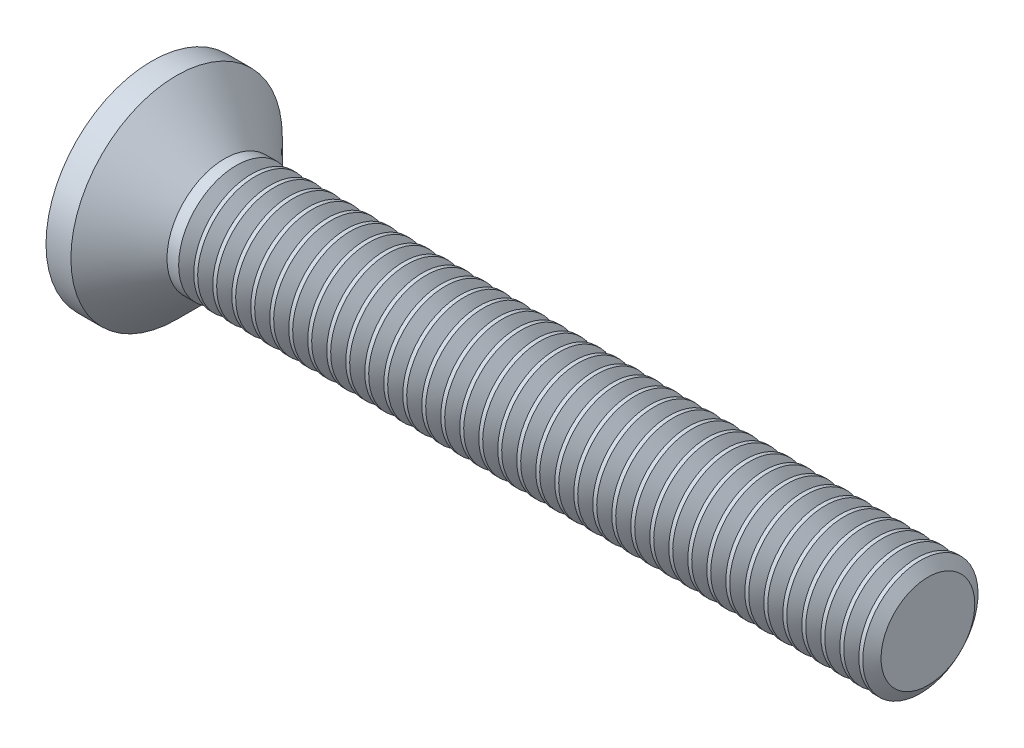
from build123d import *

# Parameters (mm, degrees)
SKETCH3_W         = 0.83
SKETCH3_H         = 3.44
SKETCH4_W         = 0.415
SKETCH4_H         = 0.415
CIRPATTERN1_COUNT = 2
CIRPATTERN1_ANGLE = 90
THDSCHPAT_COUNT   = 37
THDSCHPAT_PITCH   = 0.494444444


with BuildPart() as part:
    # BodySke → Base-Revolve (revolve)
    with BuildSketch(Plane.XY):
        with BuildLine():
            Line((0, 0), (20.727669073, 0))
            Line((20.727669073, 0), (20.727669073, 1.5))
            Line((20.727669073, 1.5), (2.427669073, 1.5))
            Line((2.427669073, 1.5), (1.177669073, 2.75))
            Line((1.177669073, 2.75), (0.529956332, 2.75))
            ThreePointArc((0.529956332, 2.75), (0.133696843, 1.400299407), (0, 0))
        make_face()
    revolve(axis=Axis((-15.875, 0, 0), (1, 0, 0)))

    # Sketch3 → Cross section 0
    with BuildSketch(Plane(origin=(0, 0, 0), x_dir=(0, 0, -1), z_dir=(1, 0, 0))):
        Rectangle(SKETCH3_W, SKETCH3_H)
    # Sketch4 → Cross section 1
    with BuildSketch(Plane(origin=(2.33, 0, 0), x_dir=(0, 0, -1), z_dir=(1, 0, 0))):
        Rectangle(SKETCH4_W, SKETCH4_H)
    cross = loft(mode=Mode.SUBTRACT)

    # CirPattern1: Cross ×2 about axis
    cirpattern1_axis = Axis((0, 0, 0), (1, 0, 0))
    for i in range(1, CIRPATTERN1_COUNT):
        add(cross.rotate(cirpattern1_axis, i * CIRPATTERN1_ANGLE / (CIRPATTERN1_COUNT - 1)), mode=Mode.SUBTRACT)

    # ThdSchSke → ThreadSchematic (revolve, cut)
    with BuildSketch(Plane.XY):
        Polygon((2.927669073, -1.2195), (2.731260858, -1.5), (2.731260858, -1.875), (3.124077287, -1.875), (3.124077287, -1.5), align=None)
    threadschematic = revolve(axis=Axis((-3.175, 0, 0), (1, 0, 0)), mode=Mode.SUBTRACT)

    # ThdSchPat: ThreadSchematic ×37
    with Locations(*[(i * THDSCHPAT_PITCH, 0, 0) for i in range(1, THDSCHPAT_COUNT)]):
        add(threadschematic, mode=Mode.SUBTRACT)


solid = part.part
